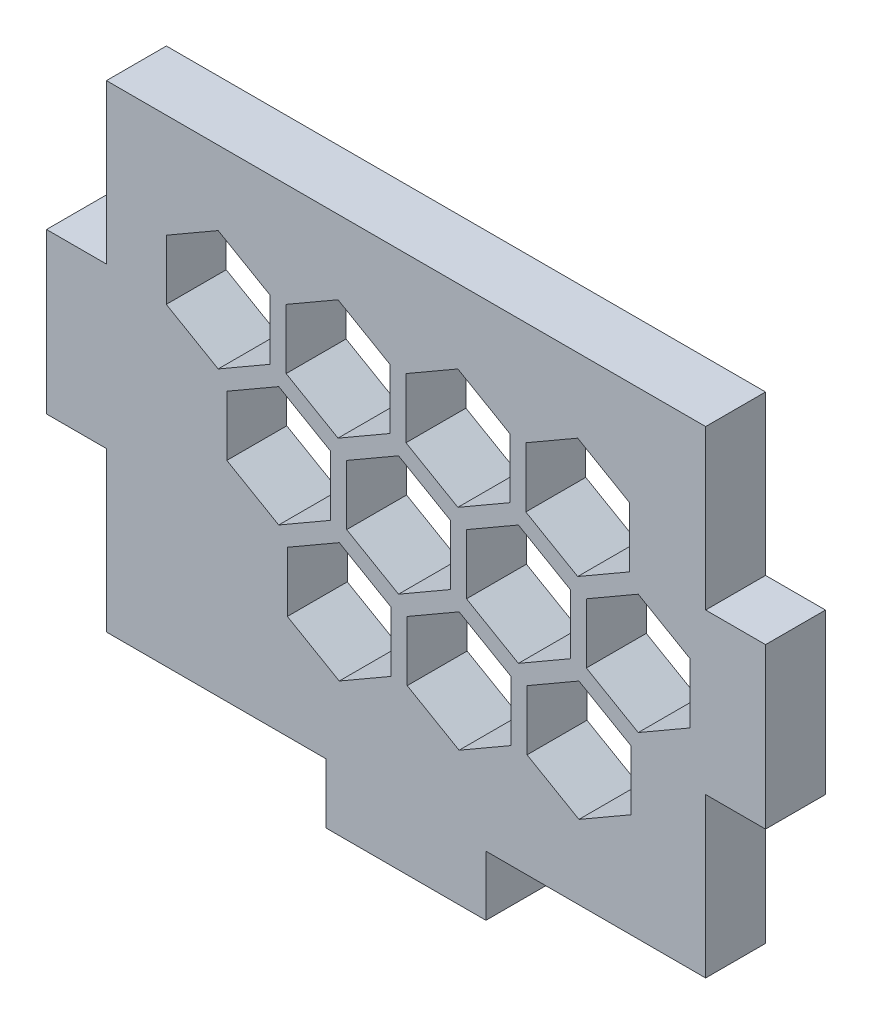
from build123d import *

# Parameters (mm, degrees)
EXTRUDE_1_DEPTH = 3


with BuildPart() as part:
    # 草图1 → 凸台-拉伸1 (new body)
    with BuildSketch(Plane.XY):
        Polygon((2696.149099258, 1909.156494091), (2696.149099258, 1917.111494091), (2707.149099258, 1917.111494091), (2715.149099258, 1917.111494091), (2726.149099258, 1917.111494091), (2726.149099258, 1909.156494091), (2729.149099258, 1909.156494091), (2729.149099258, 1901.156494091), (2726.149099258, 1901.156494091), (2726.149099258, 1893.201494091), (2715.149099258, 1893.201494091), (2715.149099258, 1890.201494091), (2707.149099258, 1890.201494091), (2707.149099258, 1893.201494091), (2696.149099258, 1893.201494091), (2696.149099258, 1901.156494091), (2693.149099258, 1901.156494091), (2693.149099258, 1909.156494091), align=None)
        Polygon((2699.145425292, 1908.906494091), (2701.743501504, 1907.406494091), (2704.341577715, 1908.906494091), (2704.341577715, 1911.906494091), (2701.743501504, 1913.406494091), (2699.145425292, 1911.906494091), align=None, mode=Mode.SUBTRACT)
        Polygon((2705.145425292, 1908.906494091), (2707.743501504, 1907.406494091), (2710.341577715, 1908.906494091), (2710.341577715, 1911.906494091), (2707.743501504, 1913.406494091), (2705.145425292, 1911.906494091), align=None, mode=Mode.SUBTRACT)
        Polygon((2711.145425292, 1908.906494091), (2713.743501504, 1907.406494091), (2716.341577715, 1908.906494091), (2716.341577715, 1911.906494091), (2713.743501504, 1913.406494091), (2711.145425292, 1911.906494091), align=None, mode=Mode.SUBTRACT)
        Polygon((2717.145425292, 1908.906494091), (2719.743501504, 1907.406494091), (2722.341577715, 1908.906494091), (2722.341577715, 1911.906494091), (2719.743501504, 1913.406494091), (2717.145425292, 1911.906494091), align=None, mode=Mode.SUBTRACT)
        Polygon((2702.176514206, 1903.656494091), (2704.774590417, 1902.156494091), (2707.372666628, 1903.656494091), (2707.372666628, 1906.656494091), (2704.774590417, 1908.156494091), (2702.176514206, 1906.656494091), align=None, mode=Mode.SUBTRACT)
        Polygon((2708.176514206, 1903.656494091), (2710.774590417, 1902.156494091), (2713.372666628, 1903.656494091), (2713.372666628, 1906.656494091), (2710.774590417, 1908.156494091), (2708.176514206, 1906.656494091), align=None, mode=Mode.SUBTRACT)
        Polygon((2714.176514206, 1903.656494091), (2716.774590417, 1902.156494091), (2719.372666628, 1903.656494091), (2719.372666628, 1906.656494091), (2716.774590417, 1908.156494091), (2714.176514206, 1906.656494091), align=None, mode=Mode.SUBTRACT)
        Polygon((2720.176514206, 1903.656494091), (2722.774590417, 1902.156494091), (2725.372666628, 1903.656494091), (2725.372666628, 1906.656494091), (2722.774590417, 1908.156494091), (2720.176514206, 1906.656494091), align=None, mode=Mode.SUBTRACT)
        Polygon((2705.207603119, 1898.406494091), (2707.80567933, 1896.906494091), (2710.403755542, 1898.406494091), (2710.403755542, 1901.406494091), (2707.80567933, 1902.906494091), (2705.207603119, 1901.406494091), align=None, mode=Mode.SUBTRACT)
        Polygon((2711.207603119, 1898.406494091), (2713.80567933, 1896.906494091), (2716.403755542, 1898.406494091), (2716.403755542, 1901.406494091), (2713.80567933, 1902.906494091), (2711.207603119, 1901.406494091), align=None, mode=Mode.SUBTRACT)
        Polygon((2717.207603119, 1898.406494091), (2719.80567933, 1896.906494091), (2722.403755542, 1898.406494091), (2722.403755542, 1901.406494091), (2719.80567933, 1902.906494091), (2717.207603119, 1901.406494091), align=None, mode=Mode.SUBTRACT)
    extrude(amount=EXTRUDE_1_DEPTH)


solid = part.part
